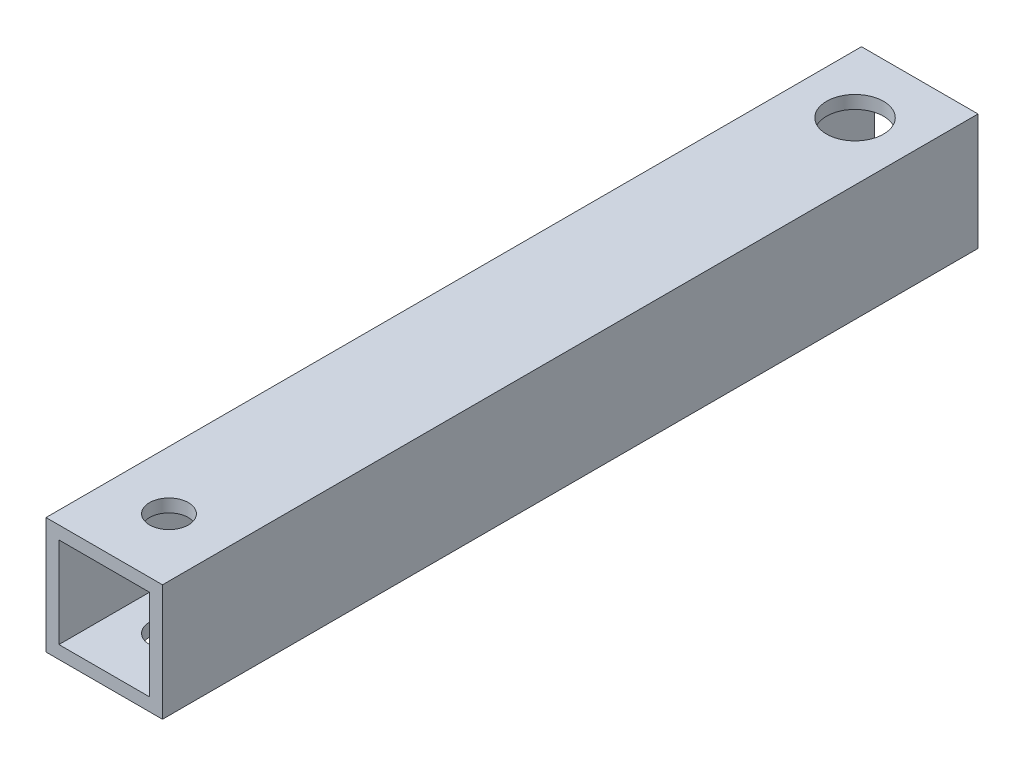
from build123d import *

# Parameters (mm, degrees)
SKETCH_1_W          = 9
SKETCH_1_H          = 9
EXTRUDE_1_DEPTH     = 63
SKETCH_2_W          = 7
SKETCH_2_H          = 7
CUT_EXTRUDE_1_DEPTH = 83
SKETCH_3_R          = 2.2
SKETCH_3_R_2        = 1.5
CUT_EXTRUDE_2_DEPTH = 93


with BuildPart() as part:
    # ｽｹｯﾁ1 → ﾎﾞｽ - 押し出し1 (new body)
    with BuildSketch(Plane.XY):
        Rectangle(SKETCH_1_W, SKETCH_1_H)
    extrude(amount=EXTRUDE_1_DEPTH)

    # ｽｹｯﾁ2 → ｶｯﾄ - 押し出し1 (cut)
    with BuildSketch(Plane.XY.offset(63)):
        Rectangle(SKETCH_2_W, SKETCH_2_H)
    extrude(amount=-CUT_EXTRUDE_1_DEPTH, mode=Mode.SUBTRACT)

    # ｽｹｯﾁ3 → ｶｯﾄ - 押し出し2 (cut)
    with BuildSketch(Plane(origin=(0, 4.5, 0), x_dir=(1, 0, 0), z_dir=(0, 1, 0))):
        with Locations((0, -5)):
            Circle(SKETCH_3_R)
        with Locations((0, -58)):
            Circle(SKETCH_3_R_2)
    extrude(amount=-CUT_EXTRUDE_2_DEPTH, mode=Mode.SUBTRACT)


solid = part.part
